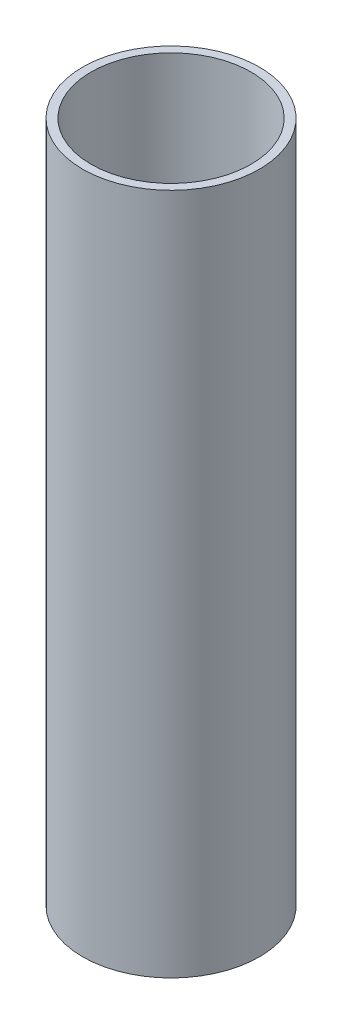
from build123d import *

# Parameters (mm, degrees)
SKETCH3_R           = 21
SKETCH3_R_2         = 19
BOSS_EXTRUDE1_DEPTH = 162


with BuildPart() as part:
    # Sketch3 → Boss-Extrude1 (new body)
    with BuildSketch(Plane(origin=(0, 0, 0), x_dir=(1, 0, 0), z_dir=(0, 1, 0))):
        Circle(SKETCH3_R)
        Circle(SKETCH3_R_2, mode=Mode.SUBTRACT)
    extrude(amount=BOSS_EXTRUDE1_DEPTH)


solid = part.part
